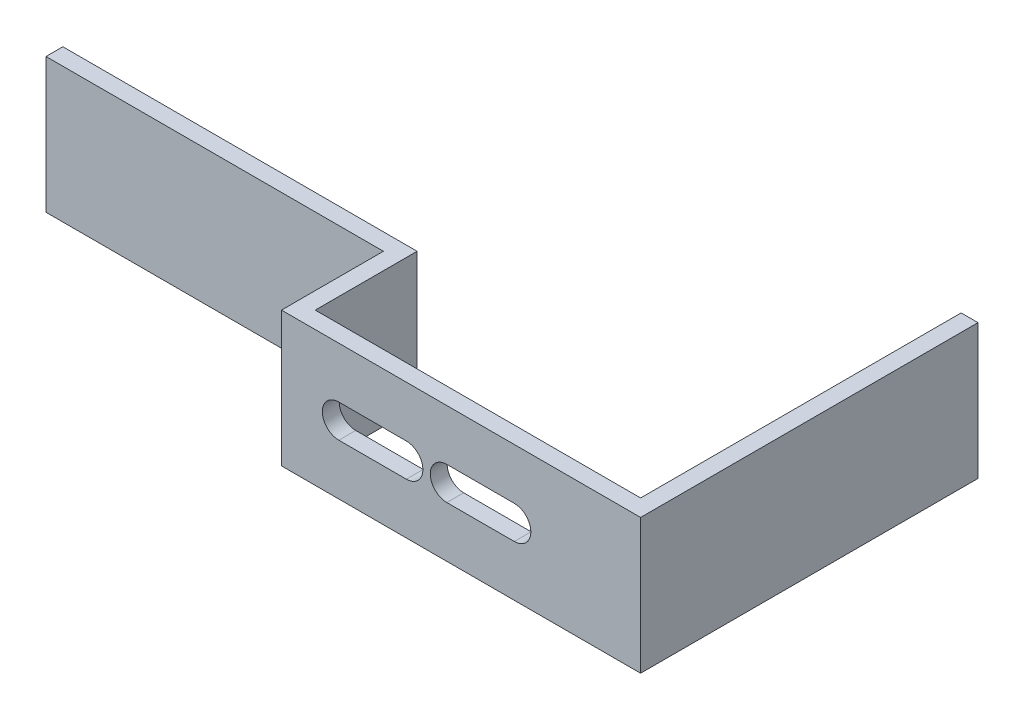
from build123d import *

# Parameters (mm, degrees)
BOSS_EXTRUDE1_DEPTH = 12.7
CUT_EXTRUDE1_DEPTH  = 32.75


with BuildPart() as part:
    # Sketch1 → Boss-Extrude1 (new body)
    with BuildSketch(Plane(origin=(0, 0, 0), x_dir=(1, 0, 0), z_dir=(0, 1, 0))):
        Polygon((0, 0), (33.7947, 0), (33.7947, 1.5875), (33.7947, 31.75), (32.2072, 31.75), (32.2072, 1.5875), (1.5875, 1.5875), (1.5875, 11.176), (0, 11.176), (-31.75, 11.176), (-31.75, 9.5885), (0, 9.5885), (0, 1.5875), align=None)
    extrude(amount=BOSS_EXTRUDE1_DEPTH)

    # Sketch2 → Cut-Extrude1 (cut, through all)
    with BuildSketch(Plane.XY):
        with BuildLine():
            Line((5.3975, 7.90575), (11.7475, 7.90575))
            ThreePointArc((11.7475, 7.90575), (13.30325, 6.35), (11.7475, 4.79425))
            Line((11.7475, 4.79425), (5.3975, 4.79425))
            ThreePointArc((5.3975, 4.79425), (3.84175, 6.35), (5.3975, 7.90575))
        make_face()
        with BuildLine():
            Line((21.9075, 7.90575), (15.5575, 7.90575))
            ThreePointArc((15.5575, 7.90575), (14.00175, 6.35), (15.5575, 4.79425))
            Line((15.5575, 4.79425), (21.9075, 4.79425))
            ThreePointArc((21.9075, 4.79425), (23.46325, 6.35), (21.9075, 7.90575))
        make_face()
    extrude(amount=-CUT_EXTRUDE1_DEPTH, mode=Mode.SUBTRACT)


solid = part.part
